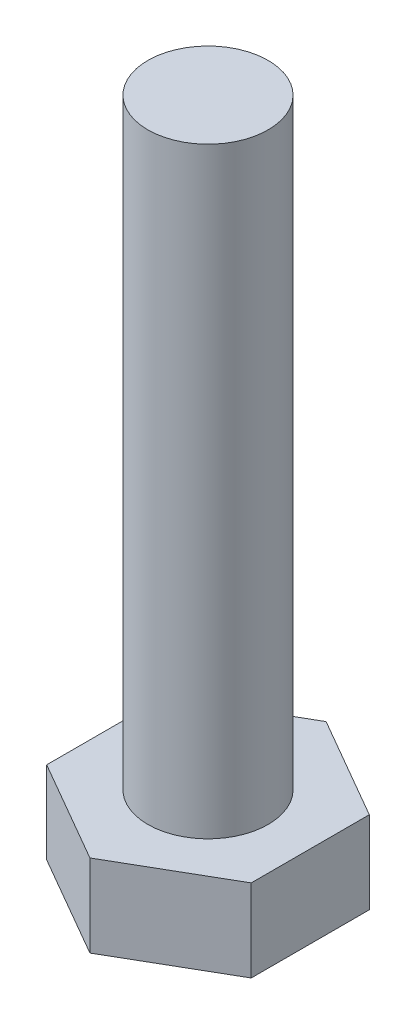
from build123d import *

# Parameters (mm, degrees)
EXTRUDE_1_DEPTH = 8
SKETCH_2_R      = 5
EXTRUDE_2_DEPTH = 50
CHAMFER_1_SIZE  = 2
CHAMFER_1_SIZE2 = 1.154700538


with BuildPart() as part:
    # Эскиз1 → Бобышка-Вытянуть1 (new body)
    with BuildSketch(Plane(origin=(0, 0, 0), x_dir=(1, 0, 0), z_dir=(0, 1, 0))):
        Polygon((8.5, -4.907477288), (8.5, 4.907477288), (0, 9.814954576), (-8.5, 4.907477288), (-8.5, -4.907477288), (0, -9.814954576), align=None)
    extrude(amount=EXTRUDE_1_DEPTH)

    # Эскиз2 → Бобышка-Вытянуть2 (add)
    with BuildSketch(Plane(origin=(0, 8, 0), x_dir=(1, 0, 0), z_dir=(0, 1, 0))):
        Circle(SKETCH_2_R)
    extrude(amount=EXTRUDE_2_DEPTH)

    # Фаска1
    chamfer_1_edges = [part.edges().sort_by_distance(p)[0] for p in [
        (-4.25, 0, 7.361215932),
        (-8.5, 0, 0),
        (-4.25, 0, -7.361215932),
        (4.25, 0, -7.361215932),
        (8.5, 0, 0),
        (4.25, 0, 7.361215932),
    ]]
    chamfer_1_side = [part.faces().sort_by_distance(p)[0] for p in [
        (0, 0, 0),
    ]]
    chamfer(chamfer_1_edges, length=CHAMFER_1_SIZE, length2=CHAMFER_1_SIZE2, reference=chamfer_1_side[0])


solid = part.part
